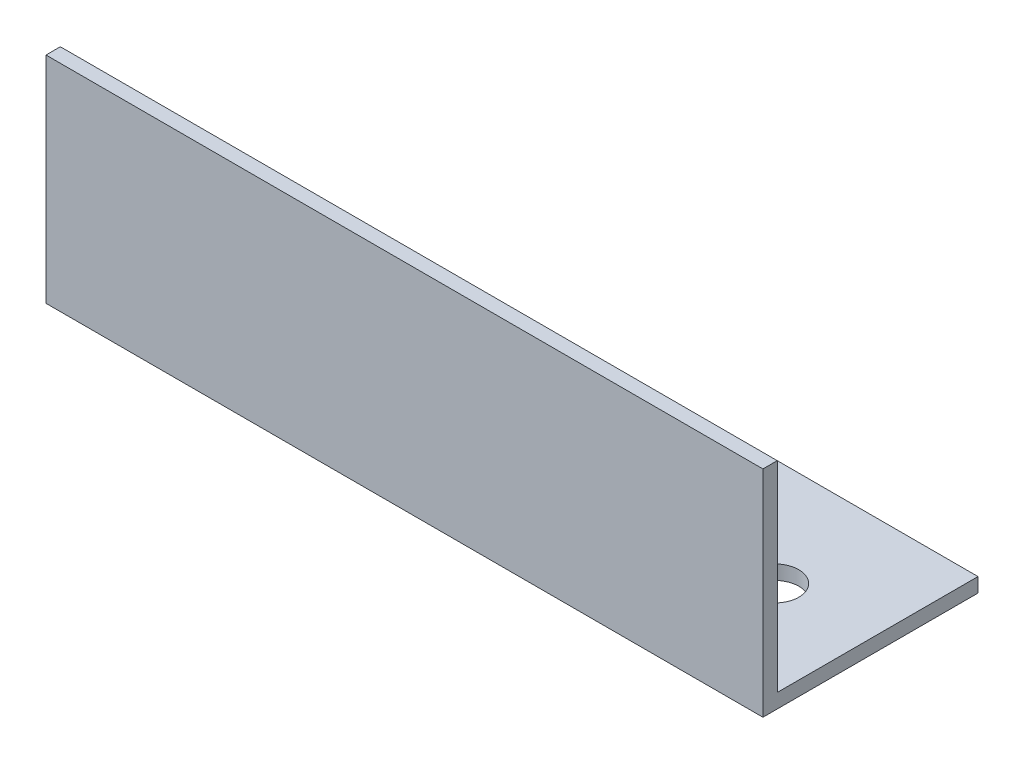
from build123d import *

# Parameters (mm, degrees)
EXTRUDE_1_DEPTH     = 150
SKETCH_2_R          = 5
CUT_EXTRUDE_1_DEPTH = 46


with BuildPart() as part:
    # Эскиз1 → Вытянуть-Тонкостенный1 (new body)
    with BuildSketch(Plane(origin=(0, 0, 0), x_dir=(0, 0, -1), z_dir=(1, 0, 0))):
        Polygon((45, 0), (0, 0), (0, 45), (3, 45), (3, 3), (45, 3), align=None)
    extrude(amount=EXTRUDE_1_DEPTH)

    # Эскиз2 → Вырез-Вытянуть1 (cut, through all)
    with BuildSketch(Plane.XZ):
        with Locations((30, -22.5)):
            Circle(SKETCH_2_R)
        with Locations((130, -22.5)):
            Circle(SKETCH_2_R)
    extrude(amount=-CUT_EXTRUDE_1_DEPTH, mode=Mode.SUBTRACT)


solid = part.part
